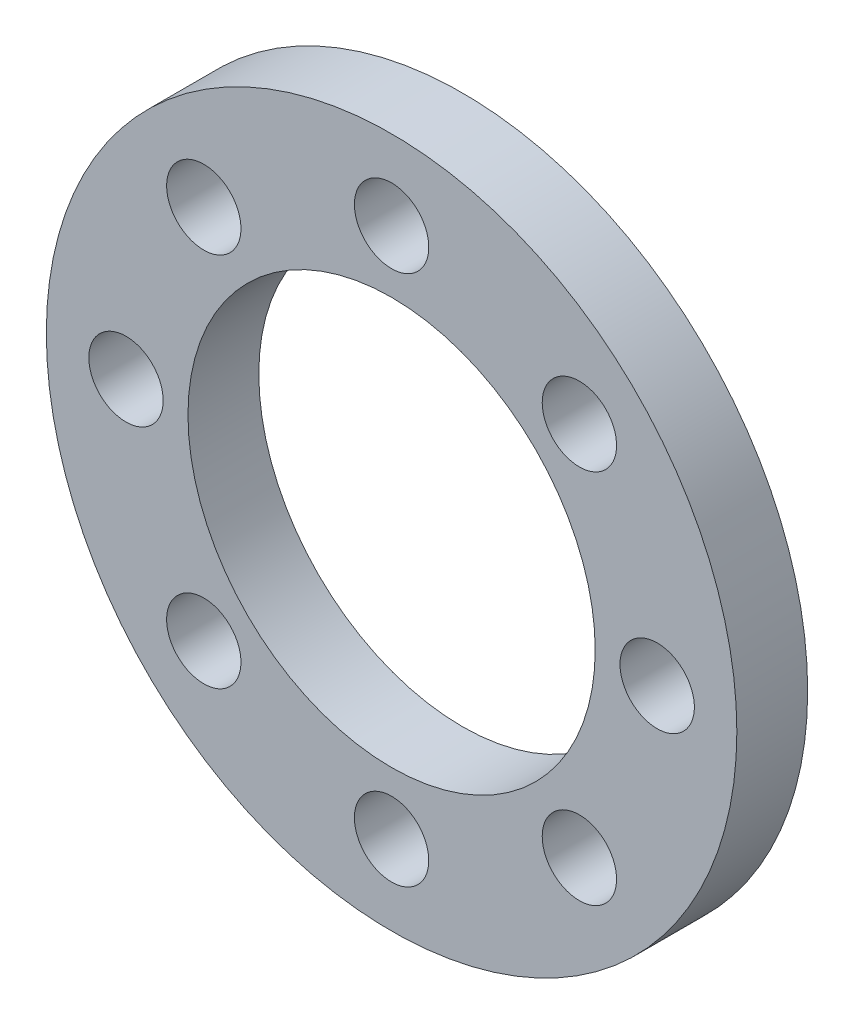
from build123d import *

# Parameters (mm, degrees)
SKETCH2_R           = 9.75
SKETCH2_R_2         = 5.75
BOSS_EXTRUDE1_DEPTH = 2
SKETCH4_R           = 1.05
CUT_EXTRUDE1_DEPTH  = 3


with BuildPart() as part:
    # Sketch2 → Boss-Extrude1 (new body)
    with BuildSketch(Plane.XY):
        Circle(SKETCH2_R)
        Circle(SKETCH2_R_2, mode=Mode.SUBTRACT)
    extrude(amount=BOSS_EXTRUDE1_DEPTH)

    # Sketch4 → Cut-Extrude1 (cut, through all)
    with BuildSketch(Plane(origin=(0, 0, 0), x_dir=(-1, 0, 0), z_dir=(0, 0, -1))):
        with Locations((0, 7.5)):
            Circle(SKETCH4_R)
        with Locations((5.303300859, 5.303300859)):
            Circle(SKETCH4_R)
        with Locations((7.5, 0)):
            Circle(SKETCH4_R)
        with Locations((5.303300859, -5.303300859)):
            Circle(SKETCH4_R)
        with Locations((0, -7.5)):
            Circle(SKETCH4_R)
        with Locations((-5.303300859, -5.303300859)):
            Circle(SKETCH4_R)
        with Locations((-7.5, 0)):
            Circle(SKETCH4_R)
        with Locations((-5.303300859, 5.303300859)):
            Circle(SKETCH4_R)
    extrude(amount=-CUT_EXTRUDE1_DEPTH, mode=Mode.SUBTRACT)


solid = part.part
